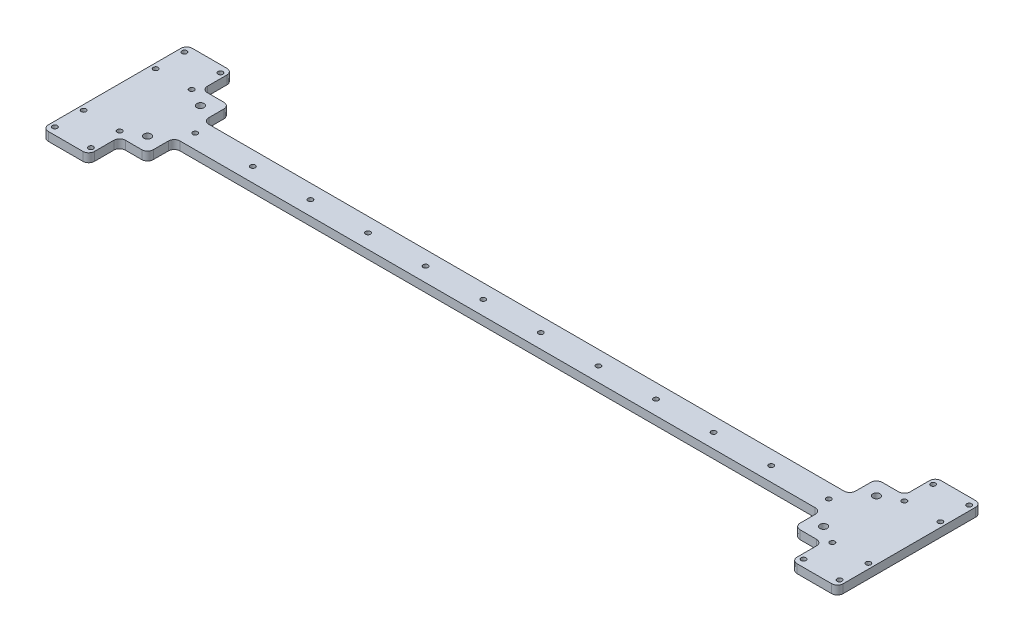
from build123d import *

# Parameters (mm, degrees)
SKETCH1_W            = 552
SKETCH1_H            = 20
BOSS_EXTRUDE1_DEPTH  = 6
SKETCH3_W            = 32
SKETCH3_H            = 100
BOSS_EXTRUDE2_DEPTH  = 6
M3_CLEARANCE_HOLE1_D = 3.4
SKETCH10_W           = 19.392395665
SKETCH10_H           = 18.526197832
SKETCH10_R           = 2.525
BOSS_EXTRUDE3_DEPTH  = 6
FILLET2_R            = 4
FILLET2_OF_MIRROR1_R = 4


with BuildPart() as part:
    # Sketch1 → Boss-Extrude1 (new body)
    with BuildSketch(Plane(origin=(0, 0, 0), x_dir=(1, 0, 0), z_dir=(0, 1, 0))):
        with Locations((276, 10)):
            Rectangle(SKETCH1_W, SKETCH1_H)
    extrude(amount=BOSS_EXTRUDE1_DEPTH)

    # Sketch3 → Boss-Extrude2 (add)
    with BuildSketch(Plane.XZ):
        with Locations((16, -10)):
            Rectangle(SKETCH3_W, SKETCH3_H)
    boss_extrude2 = extrude(amount=-BOSS_EXTRUDE2_DEPTH)

    # M3 Clearance Hole1 (through all)
    with Locations(Plane(origin=(0, 6, 0), x_dir=(1, 0, 0), z_dir=(0, 1, 0))):
        with Locations((3.5, -35), (3.5, -15), (28.5, -15), (28.5, -35), (3.5, 55), (28.5, 55), (28.5, 35), (3.5, 35), (56, 10), (96, 10), (136, 10), (176, 10), (216, 10), (256, 10)):
            m3_clearance_hole1 = Hole(M3_CLEARANCE_HOLE1_D / 2)

    # Sketch10 → Boss-Extrude3 (add)
    with BuildSketch(Plane(origin=(0, 6, 0), x_dir=(1, 0, 0), z_dir=(0, 1, 0))):
        with Locations((41.696197833, -9.263098916)):
            Rectangle(SKETCH10_W, SKETCH10_H)
        with Locations((41.232395665, -8.366197832)):
            Circle(SKETCH10_R, mode=Mode.SUBTRACT)
        with Locations((41.696197833, 29.263098916)):
            Rectangle(SKETCH10_W, SKETCH10_H)
        with Locations((41.232395665, 28.366197832)):
            Circle(SKETCH10_R, mode=Mode.SUBTRACT)
    boss_extrude3 = extrude(amount=-BOSS_EXTRUDE3_DEPTH)

    # Fillet2
    fillet2_edges = [part.edges().sort_by_distance(p)[0] for p in [
        (32, 3, 18.526197832),
        (51.392395665, 3, 0),
        (51.392395665, 3, 18.526197832),
        (32, 3, -38.526197832),
        (51.392395665, 3, -38.526197832),
        (51.392395665, 3, -20),
        (0, 3, -60),
        (32, 3, 40),
        (0, 3, 40),
        (32, 3, -60),
    ]]
    fillet(fillet2_edges, radius=FILLET2_R)

    # Mirror1: Boss-Extrude2, M3 Clearance Hole1, Boss-Extrude3 across plane
    add(boss_extrude2.mirror(Plane(origin=(276, 0, 0), x_dir=(0, 0, 1), z_dir=(1, 0, 0))))
    add(m3_clearance_hole1.mirror(Plane(origin=(276, 0, 0), x_dir=(0, 0, 1), z_dir=(1, 0, 0))), mode=Mode.SUBTRACT)
    add(boss_extrude3.mirror(Plane(origin=(276, 0, 0), x_dir=(0, 0, 1), z_dir=(1, 0, 0))))

    # Fillet2 of Mirror1
    fillet2_of_mirror1_edges = [part.edges().sort_by_distance(p)[0] for p in [
        (520, 3, 18.526197832),
        (500.607604335, 3, 0),
        (500.607604335, 3, 18.526197832),
        (520, 3, -38.526197832),
        (500.607604335, 3, -38.526197832),
        (500.607604335, 3, -20),
        (552, 3, -60),
        (520, 3, 40),
        (552, 3, 40),
        (520, 3, -60),
    ]]
    fillet(fillet2_of_mirror1_edges, radius=FILLET2_OF_MIRROR1_R)


solid = part.part
